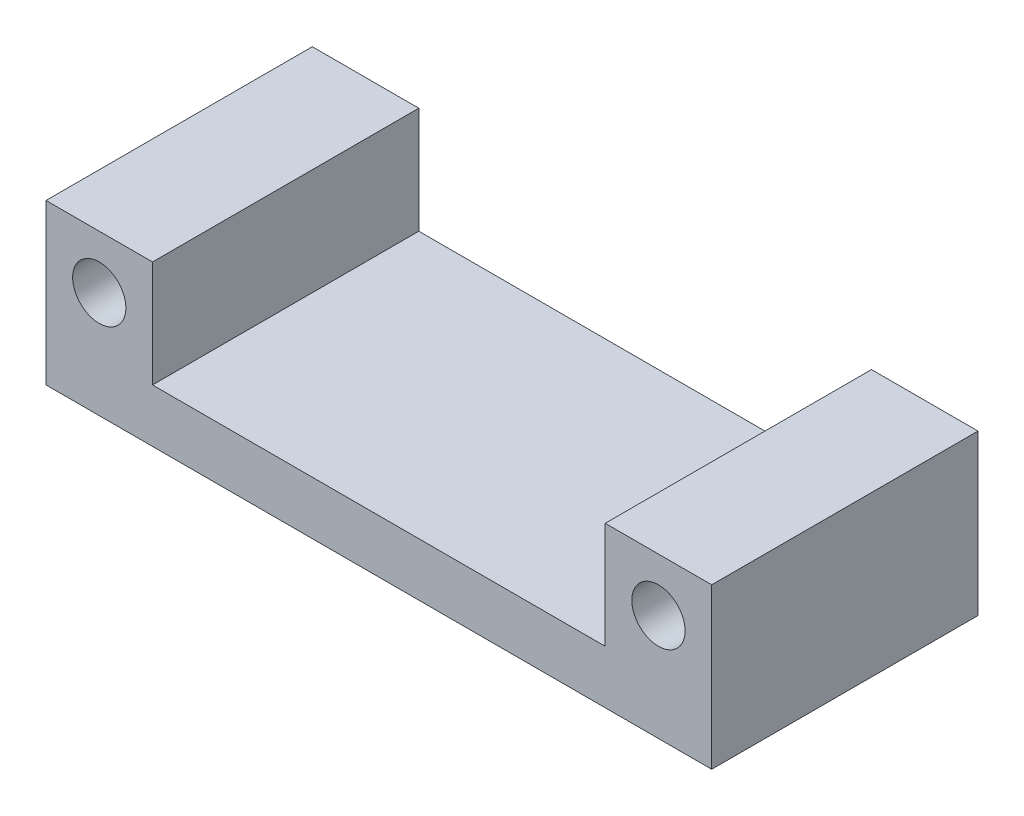
from build123d import *

# Parameters (mm, degrees)
BOSS_EXTRUDE1_DEPTH = 100
SKETCH2_R           = 10
CUT_EXTRUDE1_DEPTH  = 130


with BuildPart() as part:
    # Sketch1 → Boss-Extrude1 (new body)
    with BuildSketch(Plane.XY):
        Polygon((-125, 0), (125, 0), (125, 60), (85, 60), (85, 20), (-85, 20), (-85, 60), (-125, 60), align=None)
    extrude(amount=BOSS_EXTRUDE1_DEPTH)

    # Sketch2 → Cut-Extrude1 (cut)
    with BuildSketch(Plane.XY.offset(100)):
        with Locations((-105, 40)):
            Circle(SKETCH2_R)
        with Locations((105, 40)):
            Circle(SKETCH2_R)
    extrude(amount=-CUT_EXTRUDE1_DEPTH, mode=Mode.SUBTRACT)


solid = part.part
